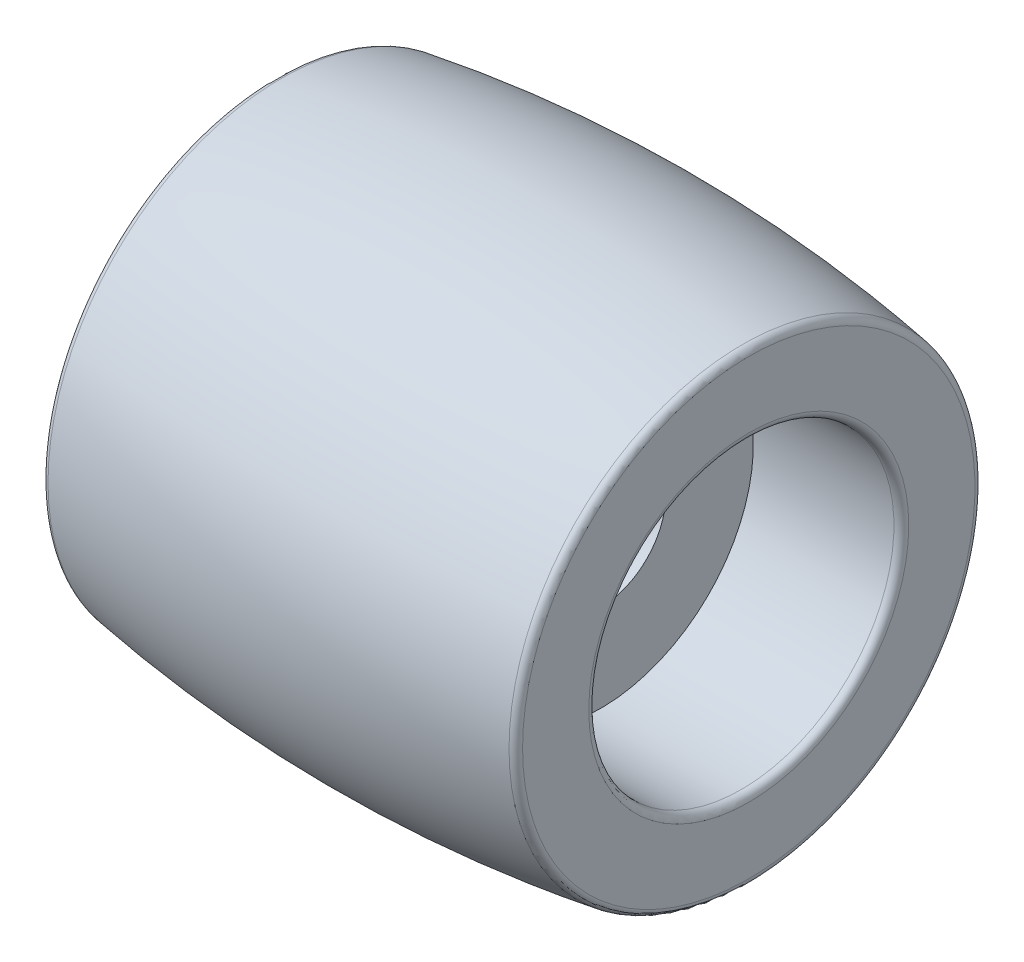
from build123d import *

# Parameters (mm, degrees)
FILLET1_R = 0.25


with BuildPart() as part:
    # Sketch1 → Revolve1 (revolve)
    with BuildSketch(Plane.XY):
        with BuildLine():
            Line((-8, 7.855850717), (-8, 5.155850717))
            Line((-8, 5.155850717), (-3, 5.155850717))
            Line((-3, 5.155850717), (-3, 2.2))
            Line((-3, 2.2), (3, 2.2))
            Line((3, 2.2), (3, 5.155850717))
            Line((3, 5.155850717), (8, 5.155850717))
            Line((8, 5.155850717), (8, 7.855850717))
            ThreePointArc((8, 7.855850717), (0, 8.5), (-8, 7.855850717))
        make_face()
    revolve(axis=Axis((-9.77367688, 0, 0), (1, 0, 0)))

    # Fillet1
    fillet1_edges = [part.edges().sort_by_distance(p)[0] for p in [
        (8, -7.855850717, 0),
        (-8, -7.855850717, 0),
        (-8, -5.155850717, 0),
        (8, -5.155850717, 0),
    ]]
    fillet(fillet1_edges, radius=FILLET1_R)


solid = part.part
